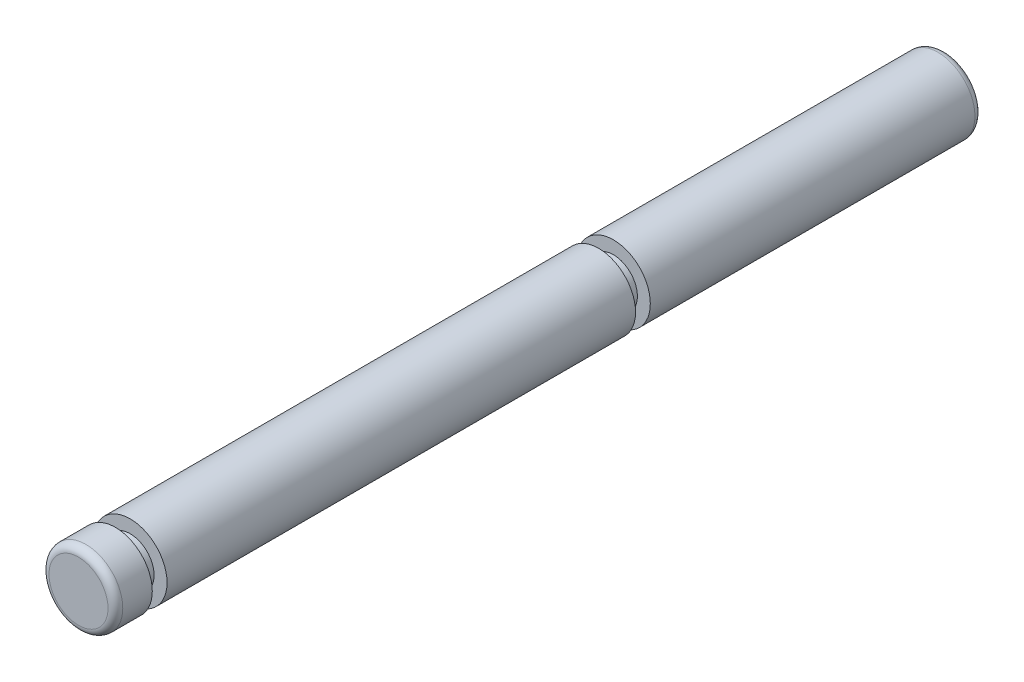
from build123d import *


with BuildPart() as part:
    # Esquisse1 → Révolution1 (revolve)
    with BuildSketch(Plane(origin=(0, 0, 0), x_dir=(0, 0, -1), z_dir=(1, 0, 0))):
        with BuildLine():
            Line((0, 0), (0, 0.8))
            ThreePointArc((0, 0.8), (-0.058578644, 0.941421356), (-0.2, 1))
            Line((-0.2, 1), (-9, 1))
            Line((-9, 1), (-9, 0.65))
            Line((-9, 0.65), (-9.4, 0.65))
            Line((-9.4, 0.65), (-9.4, 1))
            Line((-9.4, 1), (-22.1, 1))
            Line((-22.1, 1), (-22.1, 0.65))
            Line((-22.1, 0.65), (-22.5, 0.65))
            Line((-22.5, 0.65), (-22.5, 1))
            Line((-22.5, 1), (-23.3, 1))
            ThreePointArc((-23.3, 1), (-23.441421356, 0.941421356), (-23.5, 0.8))
            Line((-23.5, 0.8), (-23.5, 0))
            Line((-23.5, 0), (0, 0))
        make_face()
    revolve(axis=Axis((0, 0, 23.5), (0, 0, -1)))


solid = part.part
